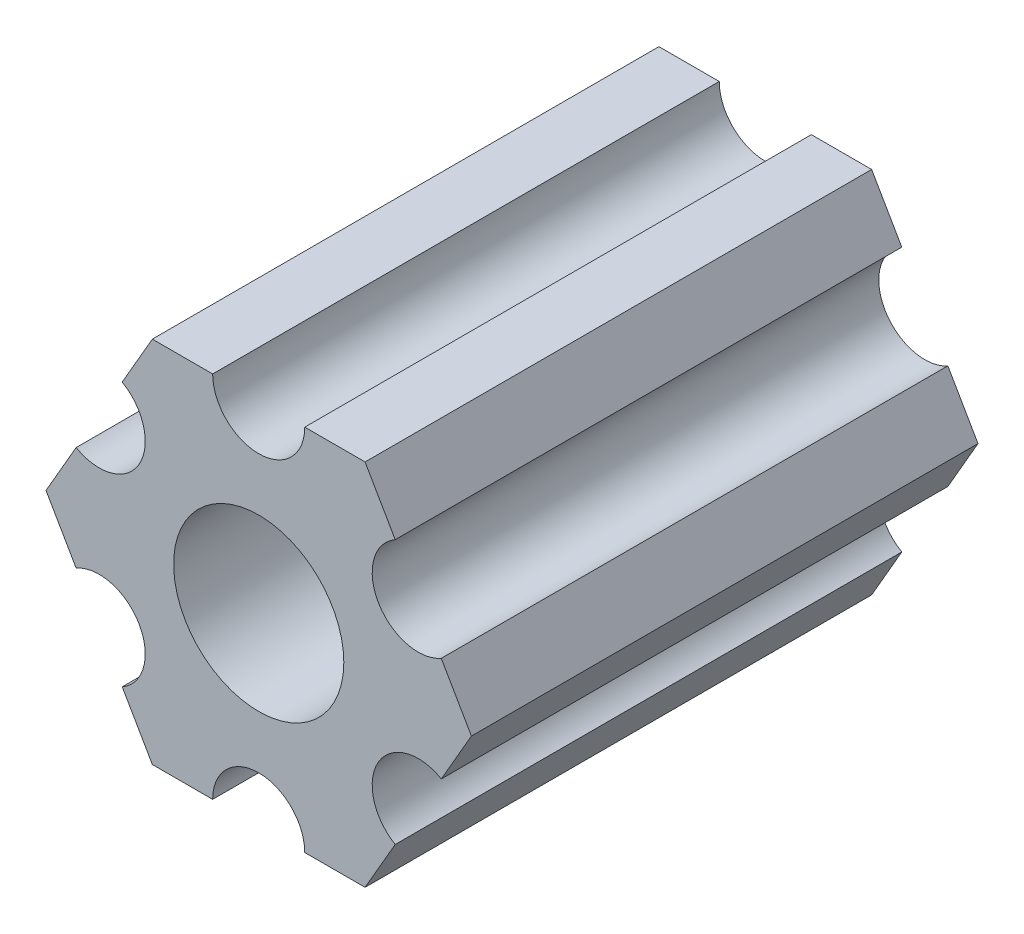
from build123d import *

# Parameters (mm, degrees)
SKETCH1_R           = 2.9337
BOSS_EXTRUDE1_DEPTH = 17.4625


with BuildPart() as part:
    # Sketch1 → Boss-Extrude1 (new body)
    with BuildSketch(Plane(origin=(0, 0, 0), x_dir=(-1, 0, 0), z_dir=(0, 0, -1))):
        with BuildLine():
            Line((-4.705511279, -4.549815428), (-3.666174225, -6.350000147))
            Line((-3.666174225, -6.350000147), (-1.5875, -6.350000147))
            ThreePointArc((-1.5875, -6.350000147), (0, -4.762500147), (1.5875, -6.350000147))
            Line((1.5875, -6.350000147), (3.666174225, -6.350000147))
            Line((3.666174225, -6.350000147), (4.705511279, -4.549815428))
            ThreePointArc((4.705511279, -4.549815428), (4.124445879, -2.381250118), (6.293011189, -1.800184719))
            Line((6.293011189, -1.800184719), (7.332348243, 0))
            Line((7.332348243, 0), (6.293011189, 1.800184719))
            ThreePointArc((6.293011189, 1.800184719), (4.124445879, 2.381250118), (4.705511279, 4.549815428))
            Line((4.705511279, 4.549815428), (3.666174225, 6.350000147))
            Line((3.666174225, 6.350000147), (1.5875, 6.350000147))
            ThreePointArc((1.5875, 6.350000147), (0, 4.762500147), (-1.5875, 6.350000147))
            Line((-1.5875, 6.350000147), (-3.666174225, 6.350000147))
            Line((-3.666174225, 6.350000147), (-4.705511279, 4.549815428))
            ThreePointArc((-4.705511279, 4.549815428), (-4.124445879, 2.381250118), (-6.293011189, 1.800184719))
            Line((-6.293011189, 1.800184719), (-7.332348243, 0))
            Line((-7.332348243, 0), (-6.293011189, -1.800184719))
            ThreePointArc((-6.293011189, -1.800184719), (-4.124445879, -2.381250118), (-4.705511279, -4.549815428))
        make_face()
        Circle(SKETCH1_R, mode=Mode.SUBTRACT)
    extrude(amount=-BOSS_EXTRUDE1_DEPTH)


solid = part.part
